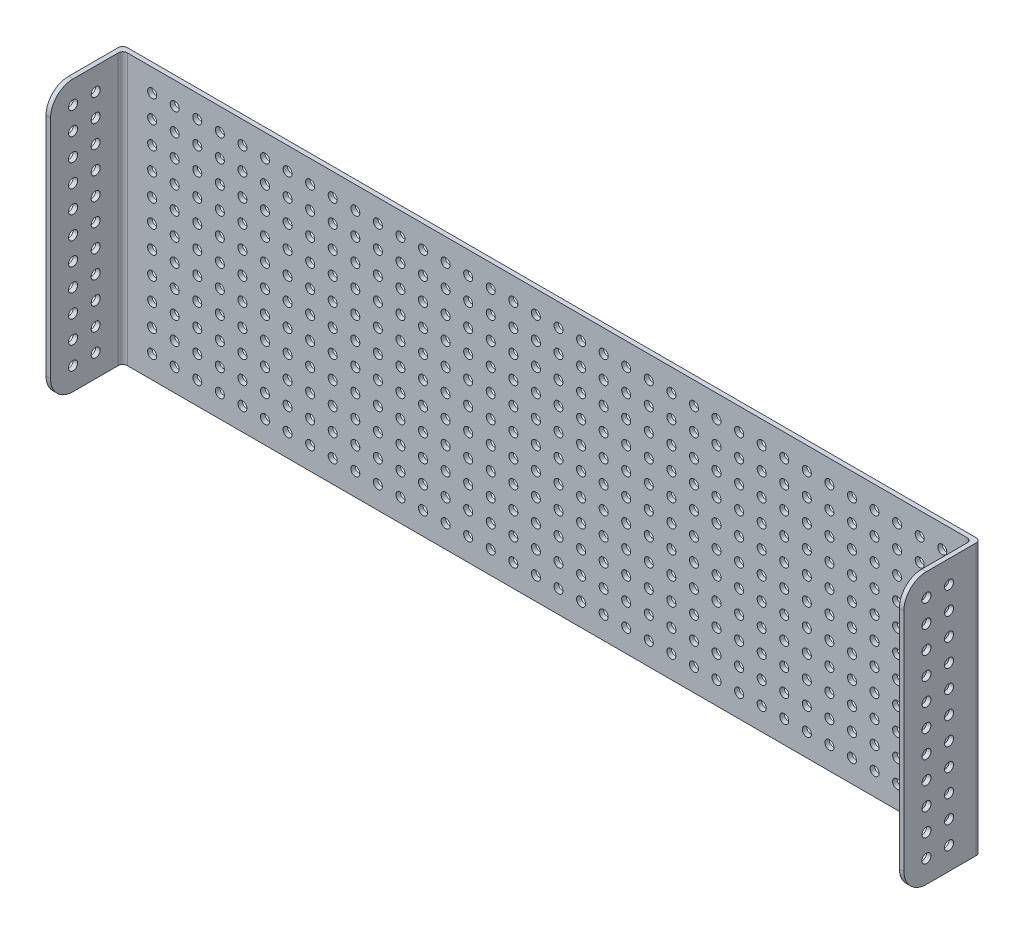
from build123d import *

# Parameters (mm, degrees)
IZIM1_W             = 380
IZIM1_H             = 120
IZIM1_R             = 2
BOSS_EXTRUDE1_DEPTH = 2
IZIM3_W             = 2
IZIM3_H             = 120
TOP_HOLES_DEPTH     = 32
IZIM4_R             = 2
CUT_EXTRUDE1_DEPTH  = 381
FILLET1_R           = 2
FILLET2_R           = 10


with BuildPart() as part:
    # Çizim1 → Boss-Extrude1 (new body)
    with BuildSketch(Plane.XY):
        with Locations((124.668181205, -33.341251384)):
            Rectangle(IZIM1_W, IZIM1_H)
        with Locations((299.668181205, 16.658748616)):
            Circle(IZIM1_R, mode=Mode.SUBTRACT)
        with Locations((289.668181205, 16.658748616)):
            Circle(IZIM1_R, mode=Mode.SUBTRACT)
        with Locations((279.668181205, 16.658748616)):
            Circle(IZIM1_R, mode=Mode.SUBTRACT)
        with Locations((269.668181205, 16.658748616)):
            Circle(IZIM1_R, mode=Mode.SUBTRACT)
        with Locations((259.668181205, 16.658748616)):
            Circle(IZIM1_R, mode=Mode.SUBTRACT)
        with Locations((249.668181205, 16.658748616)):
            Circle(IZIM1_R, mode=Mode.SUBTRACT)
        with Locations((239.668181205, 16.658748616)):
            Circle(IZIM1_R, mode=Mode.SUBTRACT)
        with Locations((229.668181205, 16.658748616)):
            Circle(IZIM1_R, mode=Mode.SUBTRACT)
        with Locations((219.668181205, 16.658748616)):
            Circle(IZIM1_R, mode=Mode.SUBTRACT)
        with Locations((209.668181205, 16.658748616)):
            Circle(IZIM1_R, mode=Mode.SUBTRACT)
        with Locations((199.668181205, 16.658748616)):
            Circle(IZIM1_R, mode=Mode.SUBTRACT)
        with Locations((189.668181205, 16.658748616)):
            Circle(IZIM1_R, mode=Mode.SUBTRACT)
        with Locations((179.668181205, 16.658748616)):
            Circle(IZIM1_R, mode=Mode.SUBTRACT)
        with Locations((169.668181205, 16.658748616)):
            Circle(IZIM1_R, mode=Mode.SUBTRACT)
        with Locations((159.668181205, 16.658748616)):
            Circle(IZIM1_R, mode=Mode.SUBTRACT)
        with Locations((149.668181205, 16.658748616)):
            Circle(IZIM1_R, mode=Mode.SUBTRACT)
        with Locations((139.668181205, 16.658748616)):
            Circle(IZIM1_R, mode=Mode.SUBTRACT)
        with Locations((129.668181205, 16.658748616)):
            Circle(IZIM1_R, mode=Mode.SUBTRACT)
        with Locations((119.668181205, 16.658748616)):
            Circle(IZIM1_R, mode=Mode.SUBTRACT)
        with Locations((109.668181205, 16.658748616)):
            Circle(IZIM1_R, mode=Mode.SUBTRACT)
        with Locations((99.668181205, 16.658748616)):
            Circle(IZIM1_R, mode=Mode.SUBTRACT)
        with Locations((89.668181205, 16.658748616)):
            Circle(IZIM1_R, mode=Mode.SUBTRACT)
        with Locations((79.668181205, 16.658748616)):
            Circle(IZIM1_R, mode=Mode.SUBTRACT)
        with Locations((69.668181205, 16.658748616)):
            Circle(IZIM1_R, mode=Mode.SUBTRACT)
        with Locations((59.668181205, 16.658748616)):
            Circle(IZIM1_R, mode=Mode.SUBTRACT)
        with Locations((49.668181205, 16.658748616)):
            Circle(IZIM1_R, mode=Mode.SUBTRACT)
        with Locations((39.668181205, 16.658748616)):
            Circle(IZIM1_R, mode=Mode.SUBTRACT)
        with Locations((29.668181205, 16.658748616)):
            Circle(IZIM1_R, mode=Mode.SUBTRACT)
        with Locations((19.668181205, 16.658748616)):
            Circle(IZIM1_R, mode=Mode.SUBTRACT)
        with Locations((9.668181205, 16.658748616)):
            Circle(IZIM1_R, mode=Mode.SUBTRACT)
        with Locations((-0.331818795, 16.658748616)):
            Circle(IZIM1_R, mode=Mode.SUBTRACT)
        with Locations((-10.331818795, 16.658748616)):
            Circle(IZIM1_R, mode=Mode.SUBTRACT)
        with Locations((-20.331818795, 16.658748616)):
            Circle(IZIM1_R, mode=Mode.SUBTRACT)
        with Locations((-30.331818795, 16.658748616)):
            Circle(IZIM1_R, mode=Mode.SUBTRACT)
        with Locations((-40.331818795, 16.658748616)):
            Circle(IZIM1_R, mode=Mode.SUBTRACT)
        with Locations((-50.331818795, 16.658748616)):
            Circle(IZIM1_R, mode=Mode.SUBTRACT)
        with Locations((289.668181205, 6.658748616)):
            Circle(IZIM1_R, mode=Mode.SUBTRACT)
        with Locations((279.668181205, 6.658748616)):
            Circle(IZIM1_R, mode=Mode.SUBTRACT)
        with Locations((269.668181205, 6.658748616)):
            Circle(IZIM1_R, mode=Mode.SUBTRACT)
        with Locations((259.668181205, 6.658748616)):
            Circle(IZIM1_R, mode=Mode.SUBTRACT)
        with Locations((249.668181205, 6.658748616)):
            Circle(IZIM1_R, mode=Mode.SUBTRACT)
        with Locations((239.668181205, 6.658748616)):
            Circle(IZIM1_R, mode=Mode.SUBTRACT)
        with Locations((229.668181205, 6.658748616)):
            Circle(IZIM1_R, mode=Mode.SUBTRACT)
        with Locations((219.668181205, 6.658748616)):
            Circle(IZIM1_R, mode=Mode.SUBTRACT)
        with Locations((209.668181205, 6.658748616)):
            Circle(IZIM1_R, mode=Mode.SUBTRACT)
        with Locations((199.668181205, 6.658748616)):
            Circle(IZIM1_R, mode=Mode.SUBTRACT)
        with Locations((189.668181205, 6.658748616)):
            Circle(IZIM1_R, mode=Mode.SUBTRACT)
        with Locations((179.668181205, 6.658748616)):
            Circle(IZIM1_R, mode=Mode.SUBTRACT)
        with Locations((169.668181205, 6.658748616)):
            Circle(IZIM1_R, mode=Mode.SUBTRACT)
        with Locations((159.668181205, 6.658748616)):
            Circle(IZIM1_R, mode=Mode.SUBTRACT)
        with Locations((149.668181205, 6.658748616)):
            Circle(IZIM1_R, mode=Mode.SUBTRACT)
        with Locations((139.668181205, 6.658748616)):
            Circle(IZIM1_R, mode=Mode.SUBTRACT)
        with Locations((129.668181205, 6.658748616)):
            Circle(IZIM1_R, mode=Mode.SUBTRACT)
        with Locations((119.668181205, 6.658748616)):
            Circle(IZIM1_R, mode=Mode.SUBTRACT)
        with Locations((109.668181205, 6.658748616)):
            Circle(IZIM1_R, mode=Mode.SUBTRACT)
        with Locations((99.668181205, 6.658748616)):
            Circle(IZIM1_R, mode=Mode.SUBTRACT)
        with Locations((89.668181205, 6.658748616)):
            Circle(IZIM1_R, mode=Mode.SUBTRACT)
        with Locations((79.668181205, 6.658748616)):
            Circle(IZIM1_R, mode=Mode.SUBTRACT)
        with Locations((69.668181205, 6.658748616)):
            Circle(IZIM1_R, mode=Mode.SUBTRACT)
        with Locations((59.668181205, 6.658748616)):
            Circle(IZIM1_R, mode=Mode.SUBTRACT)
        with Locations((49.668181205, 6.658748616)):
            Circle(IZIM1_R, mode=Mode.SUBTRACT)
        with Locations((39.668181205, 6.658748616)):
            Circle(IZIM1_R, mode=Mode.SUBTRACT)
        with Locations((29.668181205, 6.658748616)):
            Circle(IZIM1_R, mode=Mode.SUBTRACT)
        with Locations((19.668181205, 6.658748616)):
            Circle(IZIM1_R, mode=Mode.SUBTRACT)
        with Locations((9.668181205, 6.658748616)):
            Circle(IZIM1_R, mode=Mode.SUBTRACT)
        with Locations((-0.331818795, 6.658748616)):
            Circle(IZIM1_R, mode=Mode.SUBTRACT)
        with Locations((-10.331818795, 6.658748616)):
            Circle(IZIM1_R, mode=Mode.SUBTRACT)
        with Locations((-20.331818795, 6.658748616)):
            Circle(IZIM1_R, mode=Mode.SUBTRACT)
        with Locations((-30.331818795, 6.658748616)):
            Circle(IZIM1_R, mode=Mode.SUBTRACT)
        with Locations((-40.331818795, 6.658748616)):
            Circle(IZIM1_R, mode=Mode.SUBTRACT)
        with Locations((-50.331818795, 6.658748616)):
            Circle(IZIM1_R, mode=Mode.SUBTRACT)
        with Locations((289.668181205, -3.341251384)):
            Circle(IZIM1_R, mode=Mode.SUBTRACT)
        with Locations((279.668181205, -3.341251384)):
            Circle(IZIM1_R, mode=Mode.SUBTRACT)
        with Locations((269.668181205, -3.341251384)):
            Circle(IZIM1_R, mode=Mode.SUBTRACT)
        with Locations((259.668181205, -3.341251384)):
            Circle(IZIM1_R, mode=Mode.SUBTRACT)
        with Locations((249.668181205, -3.341251384)):
            Circle(IZIM1_R, mode=Mode.SUBTRACT)
        with Locations((239.668181205, -3.341251384)):
            Circle(IZIM1_R, mode=Mode.SUBTRACT)
        with Locations((229.668181205, -3.341251384)):
            Circle(IZIM1_R, mode=Mode.SUBTRACT)
        with Locations((219.668181205, -3.341251384)):
            Circle(IZIM1_R, mode=Mode.SUBTRACT)
        with Locations((209.668181205, -3.341251384)):
            Circle(IZIM1_R, mode=Mode.SUBTRACT)
        with Locations((199.668181205, -3.341251384)):
            Circle(IZIM1_R, mode=Mode.SUBTRACT)
        with Locations((189.668181205, -3.341251384)):
            Circle(IZIM1_R, mode=Mode.SUBTRACT)
        with Locations((179.668181205, -3.341251384)):
            Circle(IZIM1_R, mode=Mode.SUBTRACT)
        with Locations((169.668181205, -3.341251384)):
            Circle(IZIM1_R, mode=Mode.SUBTRACT)
        with Locations((159.668181205, -3.341251384)):
            Circle(IZIM1_R, mode=Mode.SUBTRACT)
        with Locations((149.668181205, -3.341251384)):
            Circle(IZIM1_R, mode=Mode.SUBTRACT)
        with Locations((139.668181205, -3.341251384)):
            Circle(IZIM1_R, mode=Mode.SUBTRACT)
        with Locations((129.668181205, -3.341251384)):
            Circle(IZIM1_R, mode=Mode.SUBTRACT)
        with Locations((119.668181205, -3.341251384)):
            Circle(IZIM1_R, mode=Mode.SUBTRACT)
        with Locations((109.668181205, -3.341251384)):
            Circle(IZIM1_R, mode=Mode.SUBTRACT)
        with Locations((99.668181205, -3.341251384)):
            Circle(IZIM1_R, mode=Mode.SUBTRACT)
        with Locations((89.668181205, -3.341251384)):
            Circle(IZIM1_R, mode=Mode.SUBTRACT)
        with Locations((79.668181205, -3.341251384)):
            Circle(IZIM1_R, mode=Mode.SUBTRACT)
        with Locations((69.668181205, -3.341251384)):
            Circle(IZIM1_R, mode=Mode.SUBTRACT)
        with Locations((59.668181205, -3.341251384)):
            Circle(IZIM1_R, mode=Mode.SUBTRACT)
        with Locations((49.668181205, -3.341251384)):
            Circle(IZIM1_R, mode=Mode.SUBTRACT)
        with Locations((39.668181205, -3.341251384)):
            Circle(IZIM1_R, mode=Mode.SUBTRACT)
        with Locations((29.668181205, -3.341251384)):
            Circle(IZIM1_R, mode=Mode.SUBTRACT)
        with Locations((19.668181205, -3.341251384)):
            Circle(IZIM1_R, mode=Mode.SUBTRACT)
        with Locations((9.668181205, -3.341251384)):
            Circle(IZIM1_R, mode=Mode.SUBTRACT)
        with Locations((-0.331818795, -3.341251384)):
            Circle(IZIM1_R, mode=Mode.SUBTRACT)
        with Locations((-10.331818795, -3.341251384)):
            Circle(IZIM1_R, mode=Mode.SUBTRACT)
        with Locations((-20.331818795, -3.341251384)):
            Circle(IZIM1_R, mode=Mode.SUBTRACT)
        with Locations((-30.331818795, -3.341251384)):
            Circle(IZIM1_R, mode=Mode.SUBTRACT)
        with Locations((-40.331818795, -3.341251384)):
            Circle(IZIM1_R, mode=Mode.SUBTRACT)
        with Locations((-50.331818795, -3.341251384)):
            Circle(IZIM1_R, mode=Mode.SUBTRACT)
        with Locations((289.668181205, -13.341251384)):
            Circle(IZIM1_R, mode=Mode.SUBTRACT)
        with Locations((279.668181205, -13.341251384)):
            Circle(IZIM1_R, mode=Mode.SUBTRACT)
        with Locations((269.668181205, -13.341251384)):
            Circle(IZIM1_R, mode=Mode.SUBTRACT)
        with Locations((259.668181205, -13.341251384)):
            Circle(IZIM1_R, mode=Mode.SUBTRACT)
        with Locations((249.668181205, -13.341251384)):
            Circle(IZIM1_R, mode=Mode.SUBTRACT)
        with Locations((239.668181205, -13.341251384)):
            Circle(IZIM1_R, mode=Mode.SUBTRACT)
        with Locations((229.668181205, -13.341251384)):
            Circle(IZIM1_R, mode=Mode.SUBTRACT)
        with Locations((219.668181205, -13.341251384)):
            Circle(IZIM1_R, mode=Mode.SUBTRACT)
        with Locations((209.668181205, -13.341251384)):
            Circle(IZIM1_R, mode=Mode.SUBTRACT)
        with Locations((199.668181205, -13.341251384)):
            Circle(IZIM1_R, mode=Mode.SUBTRACT)
        with Locations((189.668181205, -13.341251384)):
            Circle(IZIM1_R, mode=Mode.SUBTRACT)
        with Locations((179.668181205, -13.341251384)):
            Circle(IZIM1_R, mode=Mode.SUBTRACT)
        with Locations((169.668181205, -13.341251384)):
            Circle(IZIM1_R, mode=Mode.SUBTRACT)
        with Locations((159.668181205, -13.341251384)):
            Circle(IZIM1_R, mode=Mode.SUBTRACT)
        with Locations((149.668181205, -13.341251384)):
            Circle(IZIM1_R, mode=Mode.SUBTRACT)
        with Locations((139.668181205, -13.341251384)):
            Circle(IZIM1_R, mode=Mode.SUBTRACT)
        with Locations((129.668181205, -13.341251384)):
            Circle(IZIM1_R, mode=Mode.SUBTRACT)
        with Locations((119.668181205, -13.341251384)):
            Circle(IZIM1_R, mode=Mode.SUBTRACT)
        with Locations((109.668181205, -13.341251384)):
            Circle(IZIM1_R, mode=Mode.SUBTRACT)
        with Locations((99.668181205, -13.341251384)):
            Circle(IZIM1_R, mode=Mode.SUBTRACT)
        with Locations((89.668181205, -13.341251384)):
            Circle(IZIM1_R, mode=Mode.SUBTRACT)
        with Locations((79.668181205, -13.341251384)):
            Circle(IZIM1_R, mode=Mode.SUBTRACT)
        with Locations((69.668181205, -13.341251384)):
            Circle(IZIM1_R, mode=Mode.SUBTRACT)
        with Locations((59.668181205, -13.341251384)):
            Circle(IZIM1_R, mode=Mode.SUBTRACT)
        with Locations((49.668181205, -13.341251384)):
            Circle(IZIM1_R, mode=Mode.SUBTRACT)
        with Locations((39.668181205, -13.341251384)):
            Circle(IZIM1_R, mode=Mode.SUBTRACT)
        with Locations((29.668181205, -13.341251384)):
            Circle(IZIM1_R, mode=Mode.SUBTRACT)
        with Locations((19.668181205, -13.341251384)):
            Circle(IZIM1_R, mode=Mode.SUBTRACT)
        with Locations((9.668181205, -13.341251384)):
            Circle(IZIM1_R, mode=Mode.SUBTRACT)
        with Locations((-0.331818795, -13.341251384)):
            Circle(IZIM1_R, mode=Mode.SUBTRACT)
        with Locations((-10.331818795, -13.341251384)):
            Circle(IZIM1_R, mode=Mode.SUBTRACT)
        with Locations((-20.331818795, -13.341251384)):
            Circle(IZIM1_R, mode=Mode.SUBTRACT)
        with Locations((-30.331818795, -13.341251384)):
            Circle(IZIM1_R, mode=Mode.SUBTRACT)
        with Locations((-40.331818795, -13.341251384)):
            Circle(IZIM1_R, mode=Mode.SUBTRACT)
        with Locations((-50.331818795, -13.341251384)):
            Circle(IZIM1_R, mode=Mode.SUBTRACT)
        with Locations((289.668181205, -23.341251384)):
            Circle(IZIM1_R, mode=Mode.SUBTRACT)
        with Locations((279.668181205, -23.341251384)):
            Circle(IZIM1_R, mode=Mode.SUBTRACT)
        with Locations((269.668181205, -23.341251384)):
            Circle(IZIM1_R, mode=Mode.SUBTRACT)
        with Locations((259.668181205, -23.341251384)):
            Circle(IZIM1_R, mode=Mode.SUBTRACT)
        with Locations((249.668181205, -23.341251384)):
            Circle(IZIM1_R, mode=Mode.SUBTRACT)
        with Locations((239.668181205, -23.341251384)):
            Circle(IZIM1_R, mode=Mode.SUBTRACT)
        with Locations((229.668181205, -23.341251384)):
            Circle(IZIM1_R, mode=Mode.SUBTRACT)
        with Locations((219.668181205, -23.341251384)):
            Circle(IZIM1_R, mode=Mode.SUBTRACT)
        with Locations((209.668181205, -23.341251384)):
            Circle(IZIM1_R, mode=Mode.SUBTRACT)
        with Locations((199.668181205, -23.341251384)):
            Circle(IZIM1_R, mode=Mode.SUBTRACT)
        with Locations((189.668181205, -23.341251384)):
            Circle(IZIM1_R, mode=Mode.SUBTRACT)
        with Locations((179.668181205, -23.341251384)):
            Circle(IZIM1_R, mode=Mode.SUBTRACT)
        with Locations((169.668181205, -23.341251384)):
            Circle(IZIM1_R, mode=Mode.SUBTRACT)
        with Locations((159.668181205, -23.341251384)):
            Circle(IZIM1_R, mode=Mode.SUBTRACT)
        with Locations((149.668181205, -23.341251384)):
            Circle(IZIM1_R, mode=Mode.SUBTRACT)
        with Locations((139.668181205, -23.341251384)):
            Circle(IZIM1_R, mode=Mode.SUBTRACT)
        with Locations((129.668181205, -23.341251384)):
            Circle(IZIM1_R, mode=Mode.SUBTRACT)
        with Locations((119.668181205, -23.341251384)):
            Circle(IZIM1_R, mode=Mode.SUBTRACT)
        with Locations((109.668181205, -23.341251384)):
            Circle(IZIM1_R, mode=Mode.SUBTRACT)
        with Locations((99.668181205, -23.341251384)):
            Circle(IZIM1_R, mode=Mode.SUBTRACT)
        with Locations((89.668181205, -23.341251384)):
            Circle(IZIM1_R, mode=Mode.SUBTRACT)
        with Locations((79.668181205, -23.341251384)):
            Circle(IZIM1_R, mode=Mode.SUBTRACT)
        with Locations((69.668181205, -23.341251384)):
            Circle(IZIM1_R, mode=Mode.SUBTRACT)
        with Locations((59.668181205, -23.341251384)):
            Circle(IZIM1_R, mode=Mode.SUBTRACT)
        with Locations((49.668181205, -23.341251384)):
            Circle(IZIM1_R, mode=Mode.SUBTRACT)
        with Locations((39.668181205, -23.341251384)):
            Circle(IZIM1_R, mode=Mode.SUBTRACT)
        with Locations((29.668181205, -23.341251384)):
            Circle(IZIM1_R, mode=Mode.SUBTRACT)
        with Locations((19.668181205, -23.341251384)):
            Circle(IZIM1_R, mode=Mode.SUBTRACT)
        with Locations((9.668181205, -23.341251384)):
            Circle(IZIM1_R, mode=Mode.SUBTRACT)
        with Locations((-0.331818795, -23.341251384)):
            Circle(IZIM1_R, mode=Mode.SUBTRACT)
        with Locations((-10.331818795, -23.341251384)):
            Circle(IZIM1_R, mode=Mode.SUBTRACT)
        with Locations((-20.331818795, -23.341251384)):
            Circle(IZIM1_R, mode=Mode.SUBTRACT)
        with Locations((-30.331818795, -23.341251384)):
            Circle(IZIM1_R, mode=Mode.SUBTRACT)
        with Locations((-40.331818795, -23.341251384)):
            Circle(IZIM1_R, mode=Mode.SUBTRACT)
        with Locations((-50.331818795, -23.341251384)):
            Circle(IZIM1_R, mode=Mode.SUBTRACT)
        with Locations((289.668181205, -33.341251384)):
            Circle(IZIM1_R, mode=Mode.SUBTRACT)
        with Locations((279.668181205, -33.341251384)):
            Circle(IZIM1_R, mode=Mode.SUBTRACT)
        with Locations((269.668181205, -33.341251384)):
            Circle(IZIM1_R, mode=Mode.SUBTRACT)
        with Locations((259.668181205, -33.341251384)):
            Circle(IZIM1_R, mode=Mode.SUBTRACT)
        with Locations((249.668181205, -33.341251384)):
            Circle(IZIM1_R, mode=Mode.SUBTRACT)
        with Locations((239.668181205, -33.341251384)):
            Circle(IZIM1_R, mode=Mode.SUBTRACT)
        with Locations((229.668181205, -33.341251384)):
            Circle(IZIM1_R, mode=Mode.SUBTRACT)
        with Locations((219.668181205, -33.341251384)):
            Circle(IZIM1_R, mode=Mode.SUBTRACT)
        with Locations((209.668181205, -33.341251384)):
            Circle(IZIM1_R, mode=Mode.SUBTRACT)
        with Locations((199.668181205, -33.341251384)):
            Circle(IZIM1_R, mode=Mode.SUBTRACT)
        with Locations((189.668181205, -33.341251384)):
            Circle(IZIM1_R, mode=Mode.SUBTRACT)
        with Locations((179.668181205, -33.341251384)):
            Circle(IZIM1_R, mode=Mode.SUBTRACT)
        with Locations((169.668181205, -33.341251384)):
            Circle(IZIM1_R, mode=Mode.SUBTRACT)
        with Locations((159.668181205, -33.341251384)):
            Circle(IZIM1_R, mode=Mode.SUBTRACT)
        with Locations((149.668181205, -33.341251384)):
            Circle(IZIM1_R, mode=Mode.SUBTRACT)
        with Locations((139.668181205, -33.341251384)):
            Circle(IZIM1_R, mode=Mode.SUBTRACT)
        with Locations((129.668181205, -33.341251384)):
            Circle(IZIM1_R, mode=Mode.SUBTRACT)
        with Locations((119.668181205, -33.341251384)):
            Circle(IZIM1_R, mode=Mode.SUBTRACT)
        with Locations((109.668181205, -33.341251384)):
            Circle(IZIM1_R, mode=Mode.SUBTRACT)
        with Locations((99.668181205, -33.341251384)):
            Circle(IZIM1_R, mode=Mode.SUBTRACT)
        with Locations((89.668181205, -33.341251384)):
            Circle(IZIM1_R, mode=Mode.SUBTRACT)
        with Locations((79.668181205, -33.341251384)):
            Circle(IZIM1_R, mode=Mode.SUBTRACT)
        with Locations((69.668181205, -33.341251384)):
            Circle(IZIM1_R, mode=Mode.SUBTRACT)
        with Locations((59.668181205, -33.341251384)):
            Circle(IZIM1_R, mode=Mode.SUBTRACT)
        with Locations((49.668181205, -33.341251384)):
            Circle(IZIM1_R, mode=Mode.SUBTRACT)
        with Locations((39.668181205, -33.341251384)):
            Circle(IZIM1_R, mode=Mode.SUBTRACT)
        with Locations((29.668181205, -33.341251384)):
            Circle(IZIM1_R, mode=Mode.SUBTRACT)
        with Locations((19.668181205, -33.341251384)):
            Circle(IZIM1_R, mode=Mode.SUBTRACT)
        with Locations((9.668181205, -33.341251384)):
            Circle(IZIM1_R, mode=Mode.SUBTRACT)
        with Locations((-0.331818795, -33.341251384)):
            Circle(IZIM1_R, mode=Mode.SUBTRACT)
        with Locations((-10.331818795, -33.341251384)):
            Circle(IZIM1_R, mode=Mode.SUBTRACT)
        with Locations((-20.331818795, -33.341251384)):
            Circle(IZIM1_R, mode=Mode.SUBTRACT)
        with Locations((-30.331818795, -33.341251384)):
            Circle(IZIM1_R, mode=Mode.SUBTRACT)
        with Locations((-40.331818795, -33.341251384)):
            Circle(IZIM1_R, mode=Mode.SUBTRACT)
        with Locations((-50.331818795, -33.341251384)):
            Circle(IZIM1_R, mode=Mode.SUBTRACT)
        with Locations((289.668181205, -43.341251384)):
            Circle(IZIM1_R, mode=Mode.SUBTRACT)
        with Locations((279.668181205, -43.341251384)):
            Circle(IZIM1_R, mode=Mode.SUBTRACT)
        with Locations((269.668181205, -43.341251384)):
            Circle(IZIM1_R, mode=Mode.SUBTRACT)
        with Locations((259.668181205, -43.341251384)):
            Circle(IZIM1_R, mode=Mode.SUBTRACT)
        with Locations((249.668181205, -43.341251384)):
            Circle(IZIM1_R, mode=Mode.SUBTRACT)
        with Locations((239.668181205, -43.341251384)):
            Circle(IZIM1_R, mode=Mode.SUBTRACT)
        with Locations((229.668181205, -43.341251384)):
            Circle(IZIM1_R, mode=Mode.SUBTRACT)
        with Locations((219.668181205, -43.341251384)):
            Circle(IZIM1_R, mode=Mode.SUBTRACT)
        with Locations((209.668181205, -43.341251384)):
            Circle(IZIM1_R, mode=Mode.SUBTRACT)
        with Locations((199.668181205, -43.341251384)):
            Circle(IZIM1_R, mode=Mode.SUBTRACT)
        with Locations((189.668181205, -43.341251384)):
            Circle(IZIM1_R, mode=Mode.SUBTRACT)
        with Locations((179.668181205, -43.341251384)):
            Circle(IZIM1_R, mode=Mode.SUBTRACT)
        with Locations((169.668181205, -43.341251384)):
            Circle(IZIM1_R, mode=Mode.SUBTRACT)
        with Locations((159.668181205, -43.341251384)):
            Circle(IZIM1_R, mode=Mode.SUBTRACT)
        with Locations((149.668181205, -43.341251384)):
            Circle(IZIM1_R, mode=Mode.SUBTRACT)
        with Locations((139.668181205, -43.341251384)):
            Circle(IZIM1_R, mode=Mode.SUBTRACT)
        with Locations((129.668181205, -43.341251384)):
            Circle(IZIM1_R, mode=Mode.SUBTRACT)
        with Locations((119.668181205, -43.341251384)):
            Circle(IZIM1_R, mode=Mode.SUBTRACT)
        with Locations((109.668181205, -43.341251384)):
            Circle(IZIM1_R, mode=Mode.SUBTRACT)
        with Locations((99.668181205, -43.341251384)):
            Circle(IZIM1_R, mode=Mode.SUBTRACT)
        with Locations((89.668181205, -43.341251384)):
            Circle(IZIM1_R, mode=Mode.SUBTRACT)
        with Locations((79.668181205, -43.341251384)):
            Circle(IZIM1_R, mode=Mode.SUBTRACT)
        with Locations((69.668181205, -43.341251384)):
            Circle(IZIM1_R, mode=Mode.SUBTRACT)
        with Locations((59.668181205, -43.341251384)):
            Circle(IZIM1_R, mode=Mode.SUBTRACT)
        with Locations((49.668181205, -43.341251384)):
            Circle(IZIM1_R, mode=Mode.SUBTRACT)
        with Locations((39.668181205, -43.341251384)):
            Circle(IZIM1_R, mode=Mode.SUBTRACT)
        with Locations((29.668181205, -43.341251384)):
            Circle(IZIM1_R, mode=Mode.SUBTRACT)
        with Locations((19.668181205, -43.341251384)):
            Circle(IZIM1_R, mode=Mode.SUBTRACT)
        with Locations((9.668181205, -43.341251384)):
            Circle(IZIM1_R, mode=Mode.SUBTRACT)
        with Locations((-0.331818795, -43.341251384)):
            Circle(IZIM1_R, mode=Mode.SUBTRACT)
        with Locations((-10.331818795, -43.341251384)):
            Circle(IZIM1_R, mode=Mode.SUBTRACT)
        with Locations((-20.331818795, -43.341251384)):
            Circle(IZIM1_R, mode=Mode.SUBTRACT)
        with Locations((-30.331818795, -43.341251384)):
            Circle(IZIM1_R, mode=Mode.SUBTRACT)
        with Locations((-40.331818795, -43.341251384)):
            Circle(IZIM1_R, mode=Mode.SUBTRACT)
        with Locations((-50.331818795, -43.341251384)):
            Circle(IZIM1_R, mode=Mode.SUBTRACT)
        with Locations((289.668181205, -53.341251384)):
            Circle(IZIM1_R, mode=Mode.SUBTRACT)
        with Locations((279.668181205, -53.341251384)):
            Circle(IZIM1_R, mode=Mode.SUBTRACT)
        with Locations((269.668181205, -53.341251384)):
            Circle(IZIM1_R, mode=Mode.SUBTRACT)
        with Locations((259.668181205, -53.341251384)):
            Circle(IZIM1_R, mode=Mode.SUBTRACT)
        with Locations((249.668181205, -53.341251384)):
            Circle(IZIM1_R, mode=Mode.SUBTRACT)
        with Locations((239.668181205, -53.341251384)):
            Circle(IZIM1_R, mode=Mode.SUBTRACT)
        with Locations((229.668181205, -53.341251384)):
            Circle(IZIM1_R, mode=Mode.SUBTRACT)
        with Locations((219.668181205, -53.341251384)):
            Circle(IZIM1_R, mode=Mode.SUBTRACT)
        with Locations((209.668181205, -53.341251384)):
            Circle(IZIM1_R, mode=Mode.SUBTRACT)
        with Locations((199.668181205, -53.341251384)):
            Circle(IZIM1_R, mode=Mode.SUBTRACT)
        with Locations((189.668181205, -53.341251384)):
            Circle(IZIM1_R, mode=Mode.SUBTRACT)
        with Locations((179.668181205, -53.341251384)):
            Circle(IZIM1_R, mode=Mode.SUBTRACT)
        with Locations((169.668181205, -53.341251384)):
            Circle(IZIM1_R, mode=Mode.SUBTRACT)
        with Locations((159.668181205, -53.341251384)):
            Circle(IZIM1_R, mode=Mode.SUBTRACT)
        with Locations((149.668181205, -53.341251384)):
            Circle(IZIM1_R, mode=Mode.SUBTRACT)
        with Locations((139.668181205, -53.341251384)):
            Circle(IZIM1_R, mode=Mode.SUBTRACT)
        with Locations((129.668181205, -53.341251384)):
            Circle(IZIM1_R, mode=Mode.SUBTRACT)
        with Locations((119.668181205, -53.341251384)):
            Circle(IZIM1_R, mode=Mode.SUBTRACT)
        with Locations((109.668181205, -53.341251384)):
            Circle(IZIM1_R, mode=Mode.SUBTRACT)
        with Locations((99.668181205, -53.341251384)):
            Circle(IZIM1_R, mode=Mode.SUBTRACT)
        with Locations((89.668181205, -53.341251384)):
            Circle(IZIM1_R, mode=Mode.SUBTRACT)
        with Locations((79.668181205, -53.341251384)):
            Circle(IZIM1_R, mode=Mode.SUBTRACT)
        with Locations((69.668181205, -53.341251384)):
            Circle(IZIM1_R, mode=Mode.SUBTRACT)
        with Locations((59.668181205, -53.341251384)):
            Circle(IZIM1_R, mode=Mode.SUBTRACT)
        with Locations((49.668181205, -53.341251384)):
            Circle(IZIM1_R, mode=Mode.SUBTRACT)
        with Locations((39.668181205, -53.341251384)):
            Circle(IZIM1_R, mode=Mode.SUBTRACT)
        with Locations((29.668181205, -53.341251384)):
            Circle(IZIM1_R, mode=Mode.SUBTRACT)
        with Locations((19.668181205, -53.341251384)):
            Circle(IZIM1_R, mode=Mode.SUBTRACT)
        with Locations((9.668181205, -53.341251384)):
            Circle(IZIM1_R, mode=Mode.SUBTRACT)
        with Locations((-0.331818795, -53.341251384)):
            Circle(IZIM1_R, mode=Mode.SUBTRACT)
        with Locations((-10.331818795, -53.341251384)):
            Circle(IZIM1_R, mode=Mode.SUBTRACT)
        with Locations((-20.331818795, -53.341251384)):
            Circle(IZIM1_R, mode=Mode.SUBTRACT)
        with Locations((-30.331818795, -53.341251384)):
            Circle(IZIM1_R, mode=Mode.SUBTRACT)
        with Locations((-40.331818795, -53.341251384)):
            Circle(IZIM1_R, mode=Mode.SUBTRACT)
        with Locations((-50.331818795, -53.341251384)):
            Circle(IZIM1_R, mode=Mode.SUBTRACT)
        with Locations((289.668181205, -63.341251384)):
            Circle(IZIM1_R, mode=Mode.SUBTRACT)
        with Locations((279.668181205, -63.341251384)):
            Circle(IZIM1_R, mode=Mode.SUBTRACT)
        with Locations((269.668181205, -63.341251384)):
            Circle(IZIM1_R, mode=Mode.SUBTRACT)
        with Locations((259.668181205, -63.341251384)):
            Circle(IZIM1_R, mode=Mode.SUBTRACT)
        with Locations((249.668181205, -63.341251384)):
            Circle(IZIM1_R, mode=Mode.SUBTRACT)
        with Locations((239.668181205, -63.341251384)):
            Circle(IZIM1_R, mode=Mode.SUBTRACT)
        with Locations((229.668181205, -63.341251384)):
            Circle(IZIM1_R, mode=Mode.SUBTRACT)
        with Locations((219.668181205, -63.341251384)):
            Circle(IZIM1_R, mode=Mode.SUBTRACT)
        with Locations((209.668181205, -63.341251384)):
            Circle(IZIM1_R, mode=Mode.SUBTRACT)
        with Locations((199.668181205, -63.341251384)):
            Circle(IZIM1_R, mode=Mode.SUBTRACT)
        with Locations((189.668181205, -63.341251384)):
            Circle(IZIM1_R, mode=Mode.SUBTRACT)
        with Locations((179.668181205, -63.341251384)):
            Circle(IZIM1_R, mode=Mode.SUBTRACT)
        with Locations((169.668181205, -63.341251384)):
            Circle(IZIM1_R, mode=Mode.SUBTRACT)
        with Locations((159.668181205, -63.341251384)):
            Circle(IZIM1_R, mode=Mode.SUBTRACT)
        with Locations((149.668181205, -63.341251384)):
            Circle(IZIM1_R, mode=Mode.SUBTRACT)
        with Locations((139.668181205, -63.341251384)):
            Circle(IZIM1_R, mode=Mode.SUBTRACT)
        with Locations((129.668181205, -63.341251384)):
            Circle(IZIM1_R, mode=Mode.SUBTRACT)
        with Locations((119.668181205, -63.341251384)):
            Circle(IZIM1_R, mode=Mode.SUBTRACT)
        with Locations((109.668181205, -63.341251384)):
            Circle(IZIM1_R, mode=Mode.SUBTRACT)
        with Locations((99.668181205, -63.341251384)):
            Circle(IZIM1_R, mode=Mode.SUBTRACT)
        with Locations((89.668181205, -63.341251384)):
            Circle(IZIM1_R, mode=Mode.SUBTRACT)
        with Locations((79.668181205, -63.341251384)):
            Circle(IZIM1_R, mode=Mode.SUBTRACT)
        with Locations((69.668181205, -63.341251384)):
            Circle(IZIM1_R, mode=Mode.SUBTRACT)
        with Locations((59.668181205, -63.341251384)):
            Circle(IZIM1_R, mode=Mode.SUBTRACT)
        with Locations((49.668181205, -63.341251384)):
            Circle(IZIM1_R, mode=Mode.SUBTRACT)
        with Locations((39.668181205, -63.341251384)):
            Circle(IZIM1_R, mode=Mode.SUBTRACT)
        with Locations((29.668181205, -63.341251384)):
            Circle(IZIM1_R, mode=Mode.SUBTRACT)
        with Locations((19.668181205, -63.341251384)):
            Circle(IZIM1_R, mode=Mode.SUBTRACT)
        with Locations((9.668181205, -63.341251384)):
            Circle(IZIM1_R, mode=Mode.SUBTRACT)
        with Locations((-0.331818795, -63.341251384)):
            Circle(IZIM1_R, mode=Mode.SUBTRACT)
        with Locations((-10.331818795, -63.341251384)):
            Circle(IZIM1_R, mode=Mode.SUBTRACT)
        with Locations((-20.331818795, -63.341251384)):
            Circle(IZIM1_R, mode=Mode.SUBTRACT)
        with Locations((-30.331818795, -63.341251384)):
            Circle(IZIM1_R, mode=Mode.SUBTRACT)
        with Locations((-40.331818795, -63.341251384)):
            Circle(IZIM1_R, mode=Mode.SUBTRACT)
        with Locations((-50.331818795, -63.341251384)):
            Circle(IZIM1_R, mode=Mode.SUBTRACT)
        with Locations((289.668181205, -73.341251384)):
            Circle(IZIM1_R, mode=Mode.SUBTRACT)
        with Locations((279.668181205, -73.341251384)):
            Circle(IZIM1_R, mode=Mode.SUBTRACT)
        with Locations((269.668181205, -73.341251384)):
            Circle(IZIM1_R, mode=Mode.SUBTRACT)
        with Locations((259.668181205, -73.341251384)):
            Circle(IZIM1_R, mode=Mode.SUBTRACT)
        with Locations((249.668181205, -73.341251384)):
            Circle(IZIM1_R, mode=Mode.SUBTRACT)
        with Locations((239.668181205, -73.341251384)):
            Circle(IZIM1_R, mode=Mode.SUBTRACT)
        with Locations((229.668181205, -73.341251384)):
            Circle(IZIM1_R, mode=Mode.SUBTRACT)
        with Locations((219.668181205, -73.341251384)):
            Circle(IZIM1_R, mode=Mode.SUBTRACT)
        with Locations((209.668181205, -73.341251384)):
            Circle(IZIM1_R, mode=Mode.SUBTRACT)
        with Locations((199.668181205, -73.341251384)):
            Circle(IZIM1_R, mode=Mode.SUBTRACT)
        with Locations((189.668181205, -73.341251384)):
            Circle(IZIM1_R, mode=Mode.SUBTRACT)
        with Locations((179.668181205, -73.341251384)):
            Circle(IZIM1_R, mode=Mode.SUBTRACT)
        with Locations((169.668181205, -73.341251384)):
            Circle(IZIM1_R, mode=Mode.SUBTRACT)
        with Locations((159.668181205, -73.341251384)):
            Circle(IZIM1_R, mode=Mode.SUBTRACT)
        with Locations((149.668181205, -73.341251384)):
            Circle(IZIM1_R, mode=Mode.SUBTRACT)
        with Locations((139.668181205, -73.341251384)):
            Circle(IZIM1_R, mode=Mode.SUBTRACT)
        with Locations((129.668181205, -73.341251384)):
            Circle(IZIM1_R, mode=Mode.SUBTRACT)
        with Locations((119.668181205, -73.341251384)):
            Circle(IZIM1_R, mode=Mode.SUBTRACT)
        with Locations((109.668181205, -73.341251384)):
            Circle(IZIM1_R, mode=Mode.SUBTRACT)
        with Locations((99.668181205, -73.341251384)):
            Circle(IZIM1_R, mode=Mode.SUBTRACT)
        with Locations((89.668181205, -73.341251384)):
            Circle(IZIM1_R, mode=Mode.SUBTRACT)
        with Locations((79.668181205, -73.341251384)):
            Circle(IZIM1_R, mode=Mode.SUBTRACT)
        with Locations((69.668181205, -73.341251384)):
            Circle(IZIM1_R, mode=Mode.SUBTRACT)
        with Locations((59.668181205, -73.341251384)):
            Circle(IZIM1_R, mode=Mode.SUBTRACT)
        with Locations((49.668181205, -73.341251384)):
            Circle(IZIM1_R, mode=Mode.SUBTRACT)
        with Locations((39.668181205, -73.341251384)):
            Circle(IZIM1_R, mode=Mode.SUBTRACT)
        with Locations((29.668181205, -73.341251384)):
            Circle(IZIM1_R, mode=Mode.SUBTRACT)
        with Locations((19.668181205, -73.341251384)):
            Circle(IZIM1_R, mode=Mode.SUBTRACT)
        with Locations((9.668181205, -73.341251384)):
            Circle(IZIM1_R, mode=Mode.SUBTRACT)
        with Locations((-0.331818795, -73.341251384)):
            Circle(IZIM1_R, mode=Mode.SUBTRACT)
        with Locations((-10.331818795, -73.341251384)):
            Circle(IZIM1_R, mode=Mode.SUBTRACT)
        with Locations((-20.331818795, -73.341251384)):
            Circle(IZIM1_R, mode=Mode.SUBTRACT)
        with Locations((-30.331818795, -73.341251384)):
            Circle(IZIM1_R, mode=Mode.SUBTRACT)
        with Locations((-40.331818795, -73.341251384)):
            Circle(IZIM1_R, mode=Mode.SUBTRACT)
        with Locations((-50.331818795, -73.341251384)):
            Circle(IZIM1_R, mode=Mode.SUBTRACT)
        with Locations((289.668181205, -83.341251384)):
            Circle(IZIM1_R, mode=Mode.SUBTRACT)
        with Locations((279.668181205, -83.341251384)):
            Circle(IZIM1_R, mode=Mode.SUBTRACT)
        with Locations((269.668181205, -83.341251384)):
            Circle(IZIM1_R, mode=Mode.SUBTRACT)
        with Locations((259.668181205, -83.341251384)):
            Circle(IZIM1_R, mode=Mode.SUBTRACT)
        with Locations((249.668181205, -83.341251384)):
            Circle(IZIM1_R, mode=Mode.SUBTRACT)
        with Locations((239.668181205, -83.341251384)):
            Circle(IZIM1_R, mode=Mode.SUBTRACT)
        with Locations((229.668181205, -83.341251384)):
            Circle(IZIM1_R, mode=Mode.SUBTRACT)
        with Locations((219.668181205, -83.341251384)):
            Circle(IZIM1_R, mode=Mode.SUBTRACT)
        with Locations((209.668181205, -83.341251384)):
            Circle(IZIM1_R, mode=Mode.SUBTRACT)
        with Locations((199.668181205, -83.341251384)):
            Circle(IZIM1_R, mode=Mode.SUBTRACT)
        with Locations((189.668181205, -83.341251384)):
            Circle(IZIM1_R, mode=Mode.SUBTRACT)
        with Locations((179.668181205, -83.341251384)):
            Circle(IZIM1_R, mode=Mode.SUBTRACT)
        with Locations((169.668181205, -83.341251384)):
            Circle(IZIM1_R, mode=Mode.SUBTRACT)
        with Locations((159.668181205, -83.341251384)):
            Circle(IZIM1_R, mode=Mode.SUBTRACT)
        with Locations((149.668181205, -83.341251384)):
            Circle(IZIM1_R, mode=Mode.SUBTRACT)
        with Locations((139.668181205, -83.341251384)):
            Circle(IZIM1_R, mode=Mode.SUBTRACT)
        with Locations((129.668181205, -83.341251384)):
            Circle(IZIM1_R, mode=Mode.SUBTRACT)
        with Locations((119.668181205, -83.341251384)):
            Circle(IZIM1_R, mode=Mode.SUBTRACT)
        with Locations((109.668181205, -83.341251384)):
            Circle(IZIM1_R, mode=Mode.SUBTRACT)
        with Locations((99.668181205, -83.341251384)):
            Circle(IZIM1_R, mode=Mode.SUBTRACT)
        with Locations((89.668181205, -83.341251384)):
            Circle(IZIM1_R, mode=Mode.SUBTRACT)
        with Locations((79.668181205, -83.341251384)):
            Circle(IZIM1_R, mode=Mode.SUBTRACT)
        with Locations((69.668181205, -83.341251384)):
            Circle(IZIM1_R, mode=Mode.SUBTRACT)
        with Locations((59.668181205, -83.341251384)):
            Circle(IZIM1_R, mode=Mode.SUBTRACT)
        with Locations((49.668181205, -83.341251384)):
            Circle(IZIM1_R, mode=Mode.SUBTRACT)
        with Locations((39.668181205, -83.341251384)):
            Circle(IZIM1_R, mode=Mode.SUBTRACT)
        with Locations((29.668181205, -83.341251384)):
            Circle(IZIM1_R, mode=Mode.SUBTRACT)
        with Locations((19.668181205, -83.341251384)):
            Circle(IZIM1_R, mode=Mode.SUBTRACT)
        with Locations((9.668181205, -83.341251384)):
            Circle(IZIM1_R, mode=Mode.SUBTRACT)
        with Locations((-0.331818795, -83.341251384)):
            Circle(IZIM1_R, mode=Mode.SUBTRACT)
        with Locations((-10.331818795, -83.341251384)):
            Circle(IZIM1_R, mode=Mode.SUBTRACT)
        with Locations((-20.331818795, -83.341251384)):
            Circle(IZIM1_R, mode=Mode.SUBTRACT)
        with Locations((-30.331818795, -83.341251384)):
            Circle(IZIM1_R, mode=Mode.SUBTRACT)
        with Locations((-40.331818795, -83.341251384)):
            Circle(IZIM1_R, mode=Mode.SUBTRACT)
        with Locations((-50.331818795, -83.341251384)):
            Circle(IZIM1_R, mode=Mode.SUBTRACT)
        with Locations((299.668181205, 6.658748616)):
            Circle(IZIM1_R, mode=Mode.SUBTRACT)
        with Locations((299.668181205, -3.341251384)):
            Circle(IZIM1_R, mode=Mode.SUBTRACT)
        with Locations((299.668181205, -13.341251384)):
            Circle(IZIM1_R, mode=Mode.SUBTRACT)
        with Locations((299.668181205, -23.341251384)):
            Circle(IZIM1_R, mode=Mode.SUBTRACT)
        with Locations((299.668181205, -33.341251384)):
            Circle(IZIM1_R, mode=Mode.SUBTRACT)
        with Locations((299.668181205, -43.341251384)):
            Circle(IZIM1_R, mode=Mode.SUBTRACT)
        with Locations((299.668181205, -53.341251384)):
            Circle(IZIM1_R, mode=Mode.SUBTRACT)
        with Locations((299.668181205, -63.341251384)):
            Circle(IZIM1_R, mode=Mode.SUBTRACT)
        with Locations((299.668181205, -73.341251384)):
            Circle(IZIM1_R, mode=Mode.SUBTRACT)
        with Locations((299.668181205, -83.341251384)):
            Circle(IZIM1_R, mode=Mode.SUBTRACT)
    extrude(amount=BOSS_EXTRUDE1_DEPTH)

    # Çizim3 → Top Holes (add)
    with BuildSketch(Plane.XY.offset(2)):
        with Locations((-64.331818795, -33.341251384)):
            Rectangle(IZIM3_W, IZIM3_H)
        with Locations((313.668181205, -33.341251384)):
            Rectangle(IZIM3_W, IZIM3_H)
    extrude(amount=TOP_HOLES_DEPTH)

    # Çizim4 → Cut-Extrude1 (cut, through all)
    with BuildSketch(Plane.ZY.offset(65.331818795)):
        with Locations((14, -83.341251384)):
            Circle(IZIM4_R)
        with Locations((24, -83.341251384)):
            Circle(IZIM4_R)
        with Locations((24, -73.341251384)):
            Circle(IZIM4_R)
        with Locations((24, -63.341251384)):
            Circle(IZIM4_R)
        with Locations((24, -53.341251384)):
            Circle(IZIM4_R)
        with Locations((24, -43.341251384)):
            Circle(IZIM4_R)
        with Locations((24, -33.341251384)):
            Circle(IZIM4_R)
        with Locations((24, -23.341251384)):
            Circle(IZIM4_R)
        with Locations((24, -13.341251384)):
            Circle(IZIM4_R)
        with Locations((24, -3.341251384)):
            Circle(IZIM4_R)
        with Locations((24, 6.658748616)):
            Circle(IZIM4_R)
        with Locations((24, 16.658748616)):
            Circle(IZIM4_R)
        with Locations((14, -73.341251384)):
            Circle(IZIM4_R)
        with Locations((14, -63.341251384)):
            Circle(IZIM4_R)
        with Locations((14, -53.341251384)):
            Circle(IZIM4_R)
        with Locations((14, -43.341251384)):
            Circle(IZIM4_R)
        with Locations((14, -33.341251384)):
            Circle(IZIM4_R)
        with Locations((14, -23.341251384)):
            Circle(IZIM4_R)
        with Locations((14, -13.341251384)):
            Circle(IZIM4_R)
        with Locations((14, -3.341251384)):
            Circle(IZIM4_R)
        with Locations((14, 6.658748616)):
            Circle(IZIM4_R)
        with Locations((14, 16.658748616)):
            Circle(IZIM4_R)
    extrude(amount=-CUT_EXTRUDE1_DEPTH, mode=Mode.SUBTRACT)

    # Fillet1
    fillet1_edges = [part.edges().sort_by_distance(p)[0] for p in [
        (-63.331818795, -33.341251384, 2),
        (312.668181205, -33.341251384, 2),
        (314.668181205, -33.341251384, 0),
        (-65.331818795, -33.341251384, 0),
    ]]
    fillet(fillet1_edges, radius=FILLET1_R)

    # Fillet2
    fillet2_edges = [part.edges().sort_by_distance(p)[0] for p in [
        (-64.331818795, -93.341251384, 34),
        (-64.331818795, 26.658748616, 34),
        (313.668181205, -93.341251384, 34),
        (313.668181205, 26.658748616, 34),
    ]]
    fillet(fillet2_edges, radius=FILLET2_R)


solid = part.part
